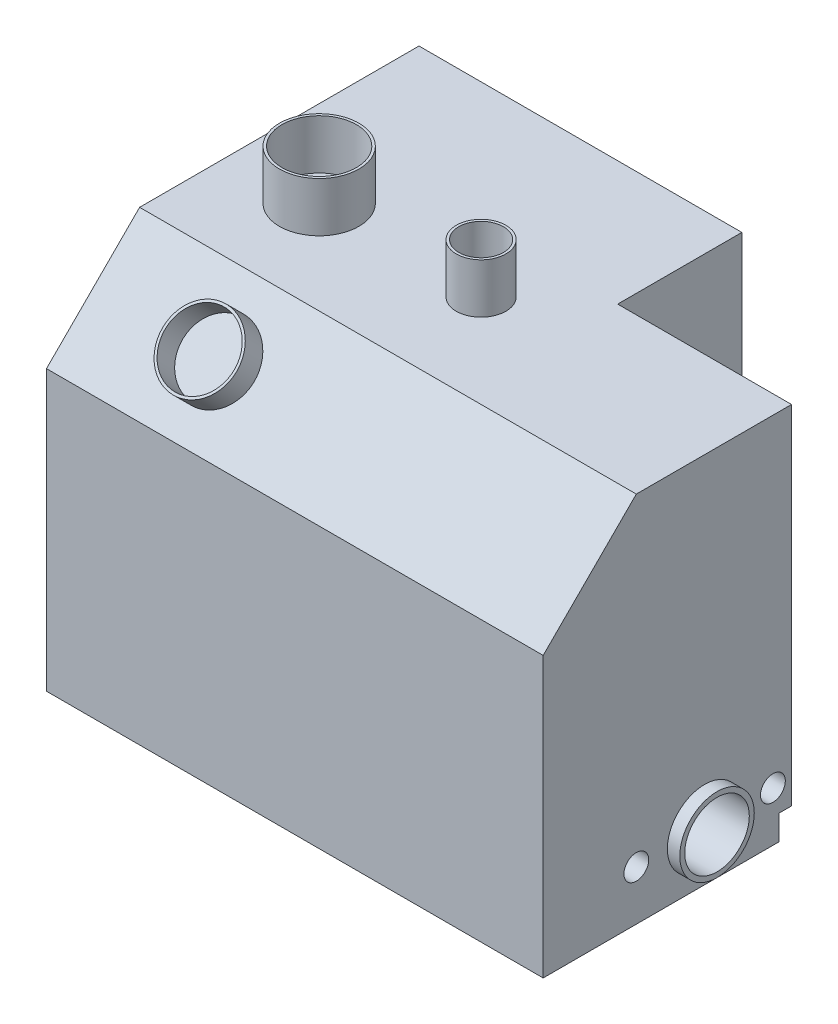
from build123d import *

# Parameters (mm, degrees)
SKETCH1_W           = 200
SKETCH1_H           = 150
BOSS_EXTRUDE1_DEPTH = 150
SKETCH2_R           = 15
SKETCH2_R_2         = 13
BOSS_EXTRUDE2_DEPTH = 5
SKETCH3_R           = 13
SKETCH3_R_2         = 5
CUT_EXTRUDE1_DEPTH  = 70
CUT_EXTRUDE2_DEPTH  = 201
SKETCH5_R           = 15
SKETCH5_R_2         = 14
BOSS_EXTRUDE3_DEPTH = 10
SKETCH7_R           = 10
SKETCH7_R_2         = 9
SKETCH7_R_3         = 16
SKETCH7_R_4         = 15
BOSS_EXTRUDE4_DEPTH = 20
SKETCH10_W          = 70
SKETCH10_H          = 50
CUT_EXTRUDE5_DEPTH  = 151


with BuildPart() as part:
    # Sketch1 → Boss-Extrude1 (new body)
    with BuildSketch(Plane(origin=(0, 0, 0), x_dir=(1, 0, 0), z_dir=(0, 1, 0))):
        Rectangle(SKETCH1_W, SKETCH1_H)
    extrude(amount=BOSS_EXTRUDE1_DEPTH)

    # Sketch2 → Boss-Extrude2 (add)
    with BuildSketch(Plane(origin=(100, 0, 0), x_dir=(0, 0, -1), z_dir=(1, 0, 0))):
        with Locations((-10, 20)):
            Circle(SKETCH2_R)
        with Locations((-10, 20)):
            Circle(SKETCH2_R_2, mode=Mode.SUBTRACT)
    extrude(amount=BOSS_EXTRUDE2_DEPTH)

    # Sketch3 → Cut-Extrude1 (cut)
    with BuildSketch(Plane(origin=(100, 0, 0), x_dir=(0, 0, -1), z_dir=(1, 0, 0))):
        with Locations((-10, 20)):
            Circle(SKETCH3_R)
        with Locations((-37.5, 20)):
            Circle(SKETCH3_R_2)
        with Locations((17.5, 20)):
            Circle(SKETCH3_R_2)
        Polygon((75, 10), (20, 10), (20, 0), (20, -30), (75, -30), (75, 0), align=None)
    extrude(amount=-CUT_EXTRUDE1_DEPTH, mode=Mode.SUBTRACT)

    # Sketch4 → Cut-Extrude2 (cut, through all)
    with BuildSketch(Plane(origin=(100, 0, 0), x_dir=(0, 0, -1), z_dir=(1, 0, 0))):
        Polygon((-37.5, 150), (-75, 112.5), (-75, 150), align=None)
    extrude(amount=-CUT_EXTRUDE2_DEPTH, mode=Mode.SUBTRACT)

    # Sketch5 → Boss-Extrude3 (add)
    with BuildSketch(Plane(origin=(0, 93.75, 93.75), x_dir=(1, 0, 0), z_dir=(0, 0.707106781, 0.707106781))):
        with Locations((-50, 53.033008589)):
            Circle(SKETCH5_R)
        with Locations((-50, 53.033008589)):
            Circle(SKETCH5_R_2, mode=Mode.SUBTRACT)
    extrude(amount=BOSS_EXTRUDE3_DEPTH)

    # Sketch7 → Boss-Extrude4 (add)
    with BuildSketch(Plane(origin=(0, 150, 0), x_dir=(1, 0, 0), z_dir=(0, 1, 0))):
        Circle(SKETCH7_R)
        Circle(SKETCH7_R_2, mode=Mode.SUBTRACT)
        with Locations((-65.196037567, 0)):
            Circle(SKETCH7_R_3)
        with Locations((-65.196037567, 0)):
            Circle(SKETCH7_R_4, mode=Mode.SUBTRACT)
    extrude(amount=BOSS_EXTRUDE4_DEPTH)

    # Sketch10 → Cut-Extrude5 (cut, through all)
    with BuildSketch(Plane(origin=(0, 150, 0), x_dir=(1, 0, 0), z_dir=(0, 1, 0))):
        with Locations((65, 50)):
            Rectangle(SKETCH10_W, SKETCH10_H)
    extrude(amount=-CUT_EXTRUDE5_DEPTH, mode=Mode.SUBTRACT)


solid = part.part
